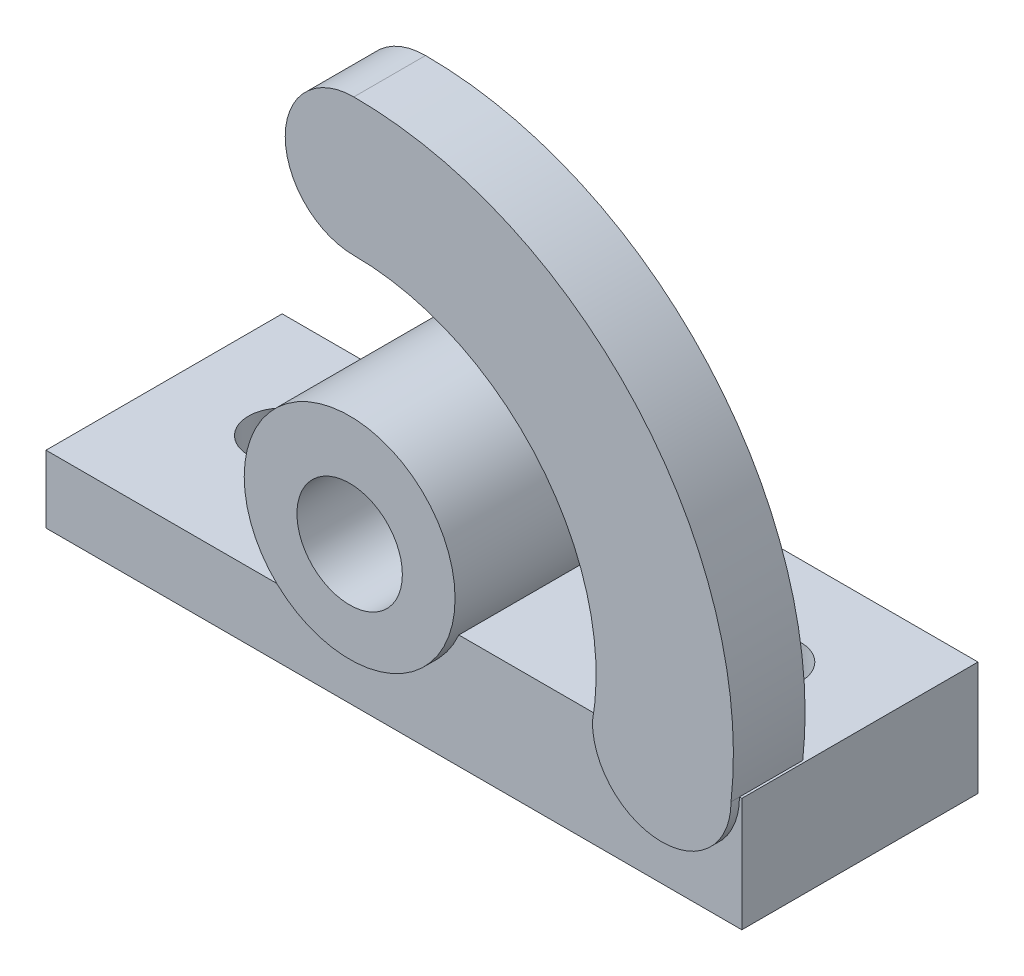
from build123d import *

# Parameters (mm, degrees)
SKETCH1_W                = 165
SKETCH1_H                = 56
BOSS_EXTRUDE1_DEPTH      = 16
SKETCH2_R                = 8
CUT_EXTRUDE1_DEPTH       = 16
SKETCH3_R                = 25
BOSS_EXTRUDE2_DEPTH      = 3
BOSS_EXTRUDE2_DEPTH_BACK = 59
FILLET1_R                = 2
SKETCH4_R                = 12.5
CUT_EXTRUDE2_DEPTH       = 63
SKETCH5_W                = 76.508877986
SKETCH5_H                = 56
SKETCH5_R                = 8
BOSS_EXTRUDE3_DEPTH      = 11
BOSS_EXTRUDE5_DEPTH      = 2
BOSS_EXTRUDE5_DEPTH_BACK = 15


with BuildPart() as part:
    # Sketch1 → Boss-Extrude1 (new body)
    with BuildSketch(Plane(origin=(0, 0, 0), x_dir=(1, 0, 0), z_dir=(0, 1, 0))):
        with Locations((82.5, 28)):
            Rectangle(SKETCH1_W, SKETCH1_H)
    extrude(amount=BOSS_EXTRUDE1_DEPTH)

    # Sketch2 → Cut-Extrude1 (cut)
    with BuildSketch(Plane(origin=(0, 16, 0), x_dir=(1, 0, 0), z_dir=(0, 1, 0))):
        with Locations((25, 31)):
            Circle(SKETCH2_R)
        with Locations((140, 31)):
            Circle(SKETCH2_R)
    extrude(amount=-CUT_EXTRUDE1_DEPTH, mode=Mode.SUBTRACT)

    # Sketch3 → Boss-Extrude2 (add, two sides)
    with BuildSketch(Plane.XY) as boss_extrude2_sk:
        with Locations((75, 37.047318756)):
            Circle(SKETCH3_R)
    extrude(amount=BOSS_EXTRUDE2_DEPTH)
    extrude(boss_extrude2_sk.sketch, amount=-BOSS_EXTRUDE2_DEPTH_BACK)

    # Fillet1
    fillet1_edges = [part.edges().sort_by_distance(p)[0] for p in [
        (61.508877986, 16, -28),
    ]]
    fillet(fillet1_edges, radius=FILLET1_R)

    # Sketch4 → Cut-Extrude2 (cut, through all)
    with BuildSketch(Plane.XY.offset(3)):
        with Locations((75, 35.713660164)):
            Circle(SKETCH4_R)
    extrude(amount=-CUT_EXTRUDE2_DEPTH, mode=Mode.SUBTRACT)

    # Sketch5 → Boss-Extrude3 (add)
    with BuildSketch(Plane(origin=(0, 16, 0), x_dir=(1, 0, 0), z_dir=(0, 1, 0))):
        with Locations((126.745561007, 28)):
            Rectangle(SKETCH5_W, SKETCH5_H)
        with Locations((140, 31)):
            Circle(SKETCH5_R, mode=Mode.SUBTRACT)
    extrude(amount=BOSS_EXTRUDE3_DEPTH)

    # Sketch8 → Boss-Extrude5 (add, two sides)
    with BuildSketch(Plane.XY) as boss_extrude5_sk:
        with BuildLine():
            ThreePointArc((75, 127.047318756), (142.097908641, 97.029571598), (164.437416028, 27))
            ThreePointArc((164.437416028, 27), (148, 10.562583972), (131.562583972, 27))
            ThreePointArc((131.562583972, 27), (119.031085874, 73.946343086), (75, 94.495334559))
            ThreePointArc((75, 94.495334559), (58.724007902, 110.771326658), (75, 127.047318756))
        make_face()
    extrude(amount=BOSS_EXTRUDE5_DEPTH)
    extrude(boss_extrude5_sk.sketch, amount=-BOSS_EXTRUDE5_DEPTH_BACK)


solid = part.part
